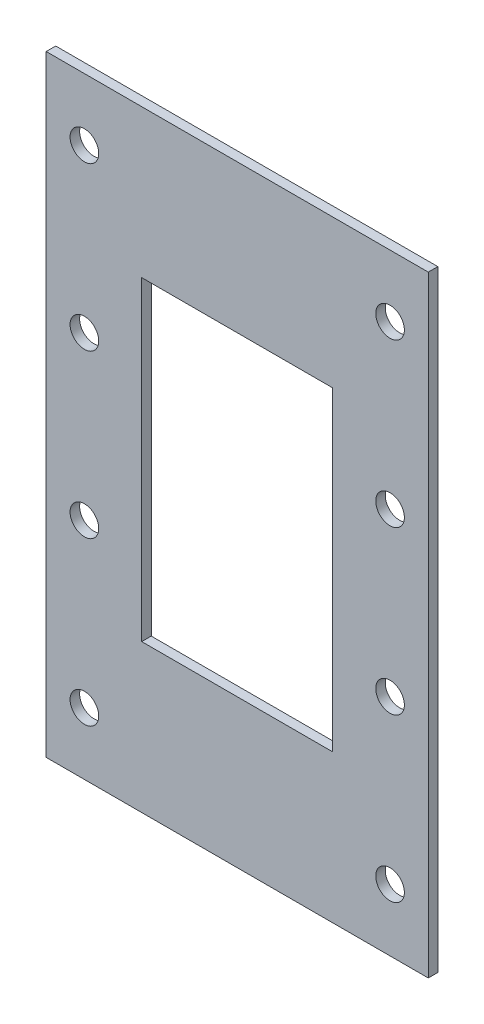
from build123d import *

# Parameters (mm, degrees)
SKETCH1_W               = 40
SKETCH1_H               = 64
BOSS_EXTRUDE1_DEPTH     = 1
SKETCH2_W               = 20
SKETCH2_H               = 33
SKETCH2_R               = 1.5
CUT_EXTRUDE1_DEPTH      = 1
CUT_EXTRUDE1_DEPTH_BACK = 2


with BuildPart() as part:
    # Sketch1 → Boss-Extrude1 (new body)
    with BuildSketch(Plane.XY):
        with Locations((20, 5.82585752)):
            Rectangle(SKETCH1_W, SKETCH1_H)
    extrude(amount=BOSS_EXTRUDE1_DEPTH)

    # Sketch2 → Cut-Extrude1 (cut, two sides)
    with BuildSketch(Plane.XY.offset(1)) as cut_extrude1_sk:
        with Locations((20, 5.82585752)):
            Rectangle(SKETCH2_W, SKETCH2_H)
        with Locations((4, -19.67414248)):
            Circle(SKETCH2_R)
        with Locations((4, -2.67414248)):
            Circle(SKETCH2_R)
        with Locations((4, 14.32585752)):
            Circle(SKETCH2_R)
        with Locations((4, 31.32585752)):
            Circle(SKETCH2_R)
        with Locations((36, -19.67414248)):
            Circle(SKETCH2_R)
        with Locations((36, -2.67414248)):
            Circle(SKETCH2_R)
        with Locations((36, 14.32585752)):
            Circle(SKETCH2_R)
        with Locations((36, 31.32585752)):
            Circle(SKETCH2_R)
    extrude(amount=CUT_EXTRUDE1_DEPTH, mode=Mode.SUBTRACT)
    extrude(cut_extrude1_sk.sketch, amount=-CUT_EXTRUDE1_DEPTH_BACK, mode=Mode.SUBTRACT)


solid = part.part
